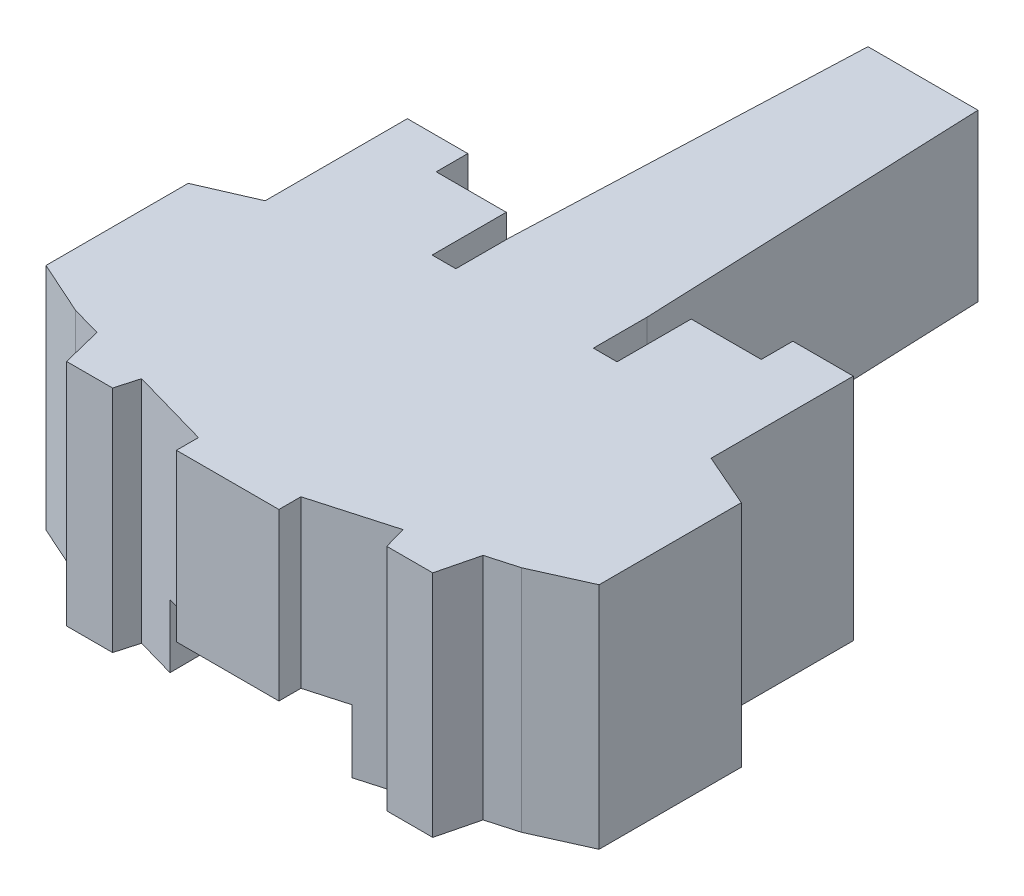
from build123d import *

# Parameters (mm, degrees)
BOSS_EXTRUDE1_DEPTH = 14.5
SKETCH2_R           = 2.5
CUT_EXTRUDE1_DEPTH  = 4


with BuildPart() as part:
    # Sketch1 → Boss-Extrude1 (new body)
    with BuildSketch(Plane(origin=(0, 0, 0), x_dir=(1, 0, 0), z_dir=(0, 1, 0))):
        Polygon((69.586467452, 65.357930026), (62.622760441, 65.357930026), (61.753444713, 43.538105233), (61.753444713, 40.147773891), (60.253444713, 40.147773891), (60.253444713, 44.839166535), (55.819934496, 44.839166535), (55.819934496, 46.839166535), (51.994945289, 46.839166535), (51.994945289, 37.839166535), (48.604613947, 36.361329796), (48.604613947, 27.361329796), (51.994945289, 25.839166535), (53.886066531, 25.301731423), (54.520425265, 22.751046211), (57.428168594, 22.751046211), (57.834181975, 24.179721996), (62.861391899, 22.751046211), (62.861391899, 21.357930026), (69.347835994, 21.357930026), (69.347835994, 22.751046211), (74.375045918, 24.179721996), (74.781059299, 22.751046211), (77.688802628, 22.751046211), (78.323161362, 25.301731423), (80.214282604, 25.839166535), (83.604613947, 27.361329796), (83.604613947, 36.361329796), (80.214282604, 37.839166535), (80.214282604, 46.839166535), (76.389293398, 46.839166535), (76.389293398, 44.839166535), (71.955783181, 44.839166535), (71.955783181, 40.147773891), (70.455783181, 40.147773891), (70.455783181, 43.538105233), align=None)
    extrude(amount=BOSS_EXTRUDE1_DEPTH)

    # Sketch2 → Cut-Extrude1 (cut)
    with BuildSketch(Plane(origin=(0, 0, 0), x_dir=(-1, 0, 0), z_dir=(0, -1, 0))):
        Polygon((-60.253444713, 40.147773891), (-60.347786937, 23.465384103), (-62.861391899, 22.751046211), (-62.861391899, 21.357930026), (-69.347835994, 21.357930026), (-69.347835994, 22.751046211), (-71.861440956, 23.465384103), (-71.955783181, 40.147773891), (-70.455783181, 40.147773891), (-70.455783181, 43.538105233), (-69.586467452, 65.357930026), (-62.622760441, 65.357930026), (-61.753444713, 43.538105233), (-61.753444713, 40.147773891), align=None)
        with Locations((-66.104613947, 40.807926742)):
            Circle(SKETCH2_R, mode=Mode.SUBTRACT)
    extrude(amount=-CUT_EXTRUDE1_DEPTH, mode=Mode.SUBTRACT)


solid = part.part
